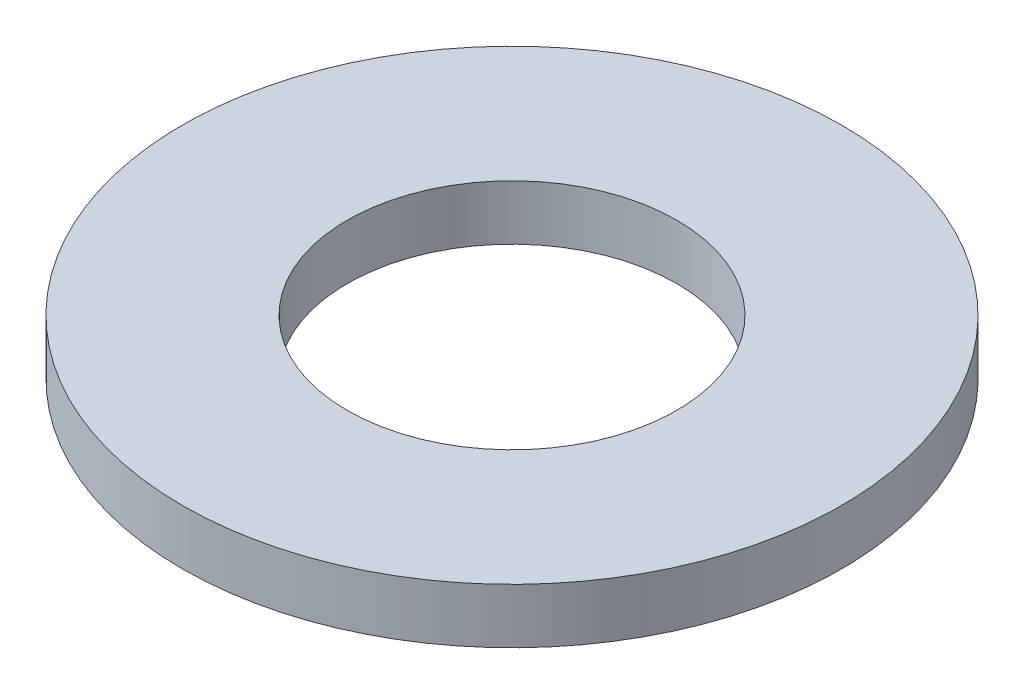
from build123d import *

# Parameters (mm, degrees)
SKETCH1_R           = 9.525
SKETCH1_R_2         = 4.7625
BOSS_EXTRUDE1_DEPTH = 1.5875


with BuildPart() as part:
    # Sketch1 → Boss-Extrude1 (new body)
    with BuildSketch(Plane(origin=(0, 0, 0), x_dir=(1, 0, 0), z_dir=(0, 1, 0))):
        Circle(SKETCH1_R)
        Circle(SKETCH1_R_2, mode=Mode.SUBTRACT)
    extrude(amount=BOSS_EXTRUDE1_DEPTH)


solid = part.part
